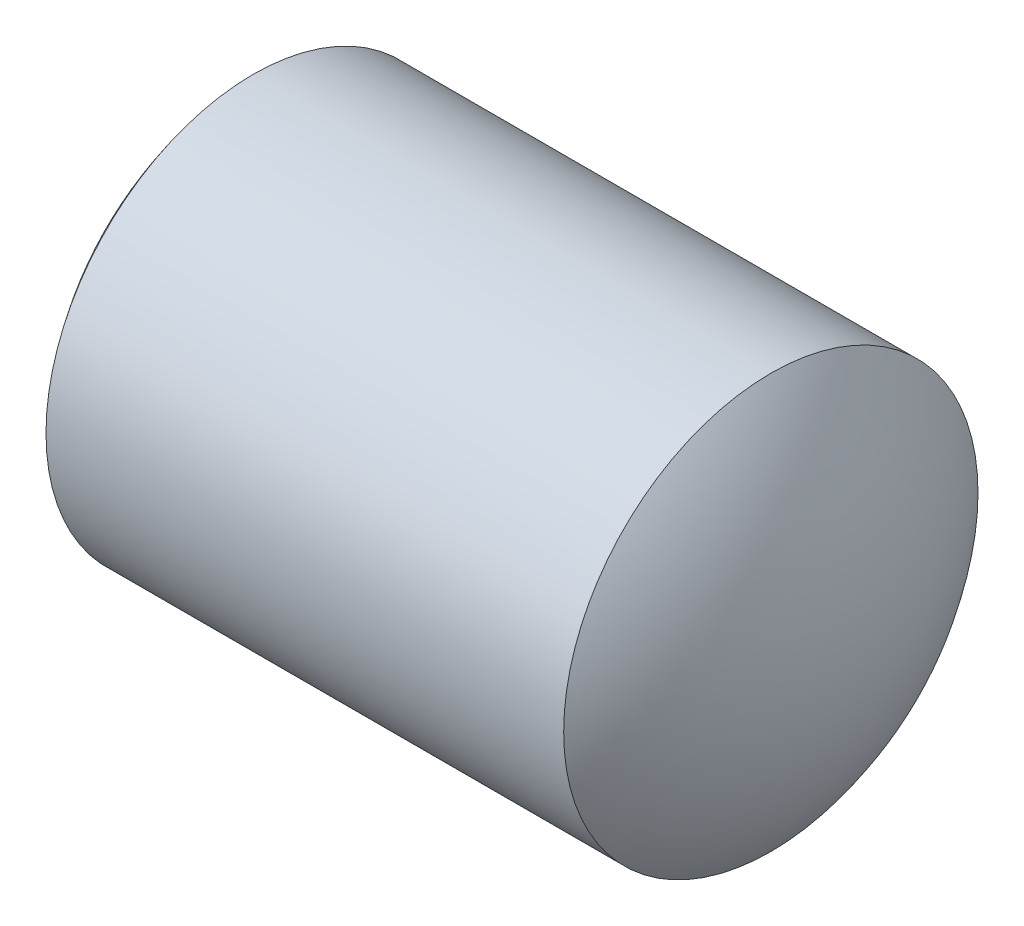
from build123d import *


with BuildPart() as part:
    # 草图1 → 旋转1 (revolve)
    with BuildSketch(Plane.XY):
        with BuildLine():
            Line((-3.122904182, 2.499493843), (3.122904182, 2.499493843))
            ThreePointArc((3.122904182, 2.499493843), (3.774361981, 1.324458998), (4, 0))
            Line((4, 0), (-4, 0))
            ThreePointArc((-4, 0), (-3.774361981, 1.324458998), (-3.122904182, 2.499493843))
        make_face()
    revolve(axis=Axis((-4.63604152, 0, 0), (1, 0, 0)))


solid = part.part
